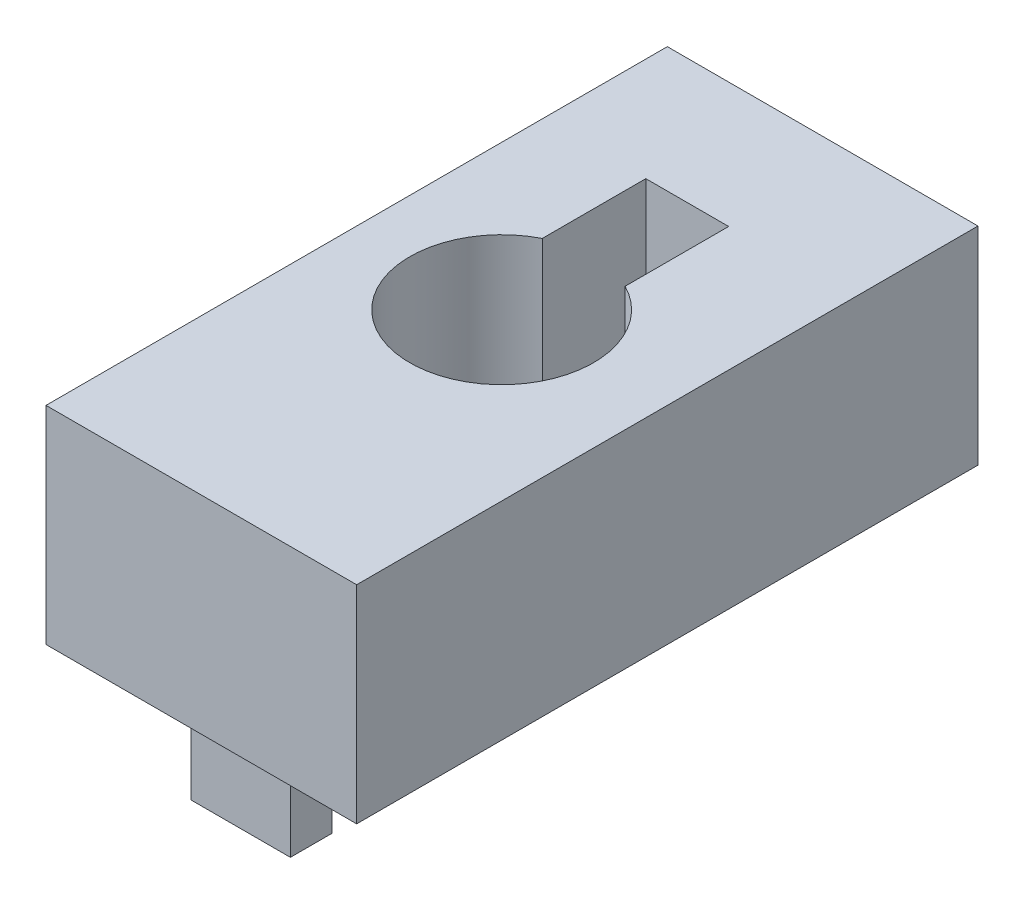
from build123d import *

# Parameters (mm, degrees)
BOSS_EXTRUDE1_DEPTH       = 12.7
SKETCH2_R                 = 5.635000033
HAPTIC_MOTOR_CUTOUT_DEPTH = 9.557999934
SKETCH3_W                 = 5.08
SKETCH3_H                 = 6.35
HAPTIC_WIRE_CUTOUT_DEPTH  = 45.45
SKETCH4_W                 = 6.096
SKETCH4_H                 = 2.54
PINS_DEPTH                = 5.08


with BuildPart() as part:
    # Sketch1 → Boss-Extrude1 (new body)
    with BuildSketch(Plane(origin=(0, 0, 0), x_dir=(1, 0, 0), z_dir=(0, 1, 0))):
        Polygon((0, 0), (19.05, 0), (19.05, 19.05), (19.05, 38.1), (0, 38.1), (0, 19.05), align=None)
    extrude(amount=BOSS_EXTRUDE1_DEPTH)

    # Sketch2 → Haptic Motor Cutout (cut)
    with BuildSketch(Plane.XZ.offset(-12.7)):
        with Locations((8.89, -19.05)):
            Circle(SKETCH2_R)
    extrude(amount=HAPTIC_MOTOR_CUTOUT_DEPTH, mode=Mode.SUBTRACT)

    # Sketch3 → Haptic Wire Cutout (cut, through all)
    with BuildSketch(Plane.XZ):
        with Locations((8.89, -27.255072104)):
            Rectangle(SKETCH3_W, SKETCH3_H)
    extrude(amount=-HAPTIC_WIRE_CUTOUT_DEPTH, mode=Mode.SUBTRACT)

    # Sketch4 → Pins (add)
    with BuildSketch(Plane.XZ):
        with Locations((10.668, -35.56)):
            Rectangle(SKETCH4_W, SKETCH4_H)
    pins = extrude(amount=PINS_DEPTH)

    # Mirror1: Pins across plane
    add(pins.mirror(Plane(origin=(0, 0, -19.05), x_dir=(1, 0, 0), z_dir=(0, 0, -1))))


solid = part.part
